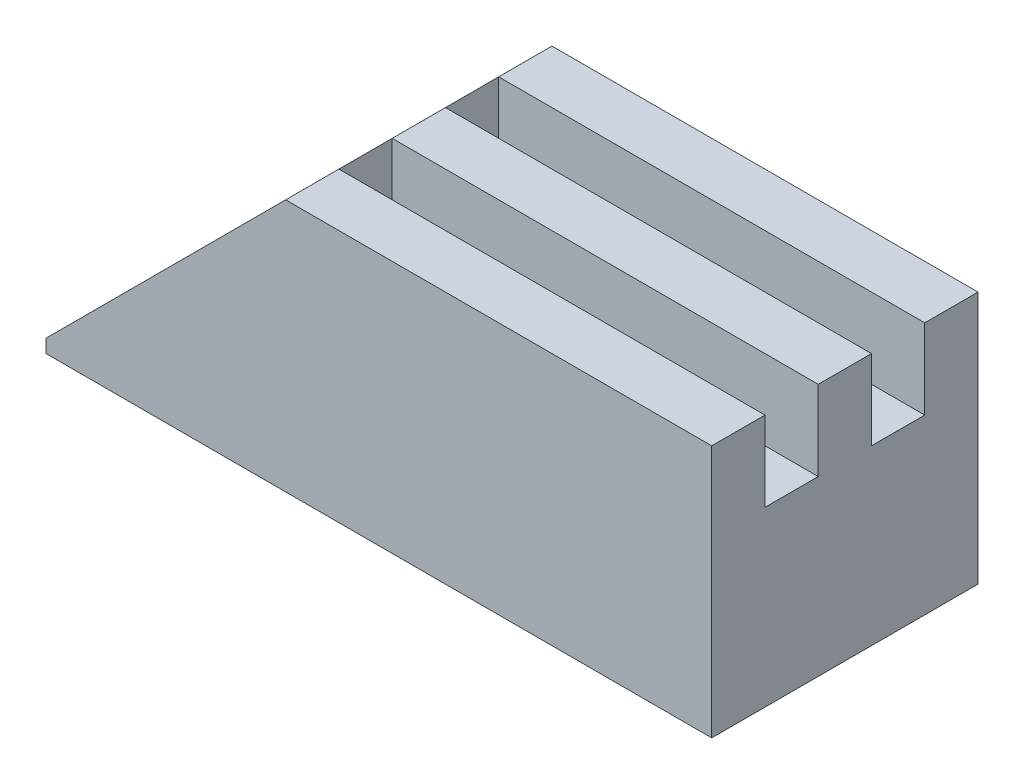
from build123d import *

# Parameters (mm, degrees)
SKETCH1_W           = 25
SKETCH1_H           = 10
BOSS_EXTRUDE1_DEPTH = 9.5
CHAMFER1_SIZE       = 9
SKETCH3_W           = 16
SKETCH3_H           = 2
CUT_EXTRUDE2_DEPTH  = 3
SKETCH4_R           = 1.25
CUT_EXTRUDE3_DEPTH  = 4


with BuildPart() as part:
    # Sketch1 → Boss-Extrude1 (new body)
    with BuildSketch(Plane(origin=(0, 0, 0), x_dir=(1, 0, 0), z_dir=(0, 1, 0))):
        Rectangle(SKETCH1_W, SKETCH1_H)
    extrude(amount=BOSS_EXTRUDE1_DEPTH)

    # Chamfer1
    chamfer1_edges = [part.edges().sort_by_distance(p)[0] for p in [
        (-12.5, 9.5, 0),
    ]]
    chamfer(chamfer1_edges, length=CHAMFER1_SIZE)

    # Sketch3 → Cut-Extrude2 (cut)
    with BuildSketch(Plane(origin=(0, 9.5, 0), x_dir=(1, 0, 0), z_dir=(0, 1, 0))):
        with Locations((4.5, 2)):
            Rectangle(SKETCH3_W, SKETCH3_H)
        with Locations((4.5, -2)):
            Rectangle(SKETCH3_W, SKETCH3_H)
    extrude(amount=-CUT_EXTRUDE2_DEPTH, mode=Mode.SUBTRACT)

    # Sketch4 → Cut-Extrude3 (cut)
    with BuildSketch(Plane(origin=(-6.5, 6.5, 0), x_dir=(0, 0, 1), z_dir=(-0.707106781, 0.707106781, 0))):
        with Locations((0, 1.392640687)):
            Circle(SKETCH4_R)
    extrude(amount=-CUT_EXTRUDE3_DEPTH, mode=Mode.SUBTRACT)


solid = part.part
